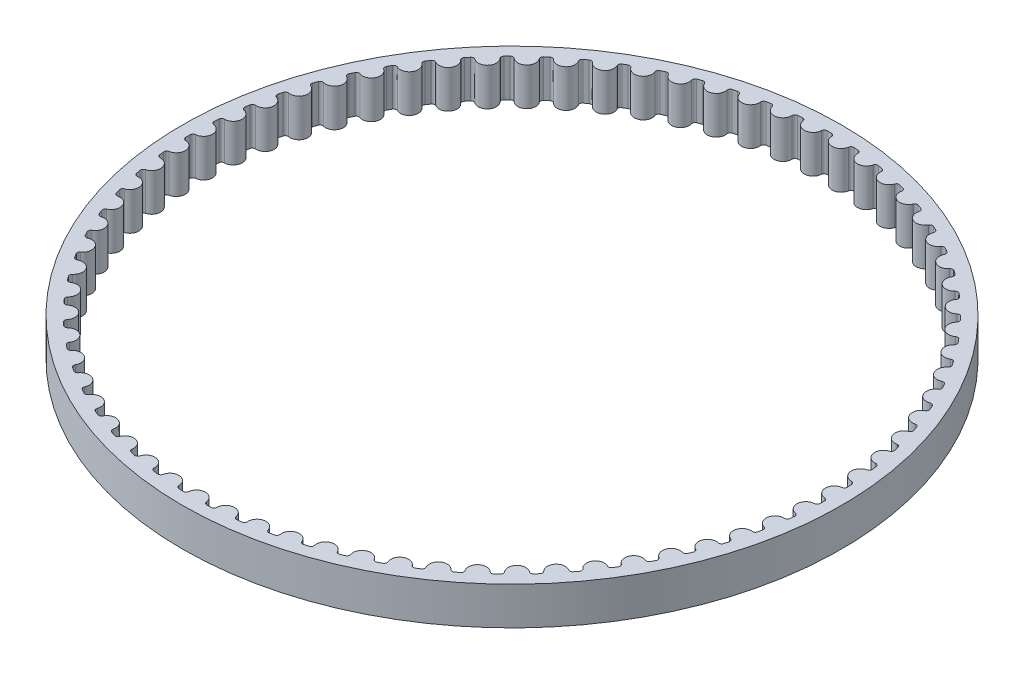
from build123d import *

# Parameters (mm, degrees)
SKETCH1_R           = 34.819002879
BOSS_EXTRUDE1_DEPTH = 4


with BuildPart() as part:
    # Sketch1 → Boss-Extrude1 (new body)
    with BuildSketch(Plane(origin=(0, 0, 0), x_dir=(1, 0, 0), z_dir=(0, 1, 0))):
        Circle(SKETCH1_R)
        with BuildLine():
            ThreePointArc((-1.717893516, -33.474951768), (-1.482657676, -33.486195367), (-1.247348646, -33.495785934))
            ThreePointArc((-1.247348646, -33.495785934), (-1.040464192, -33.423001703), (-0.938899541, -33.228622323))
            ThreePointArc((-0.938899541, -33.228622323), (0, -32.384305614), (0.938899541, -33.228622323))
            ThreePointArc((0.938899541, -33.228622323), (1.040464192, -33.423001703), (1.247348646, -33.495785934))
            ThreePointArc((1.247348646, -33.495785934), (1.482657676, -33.486195367), (1.717893516, -33.474951768))
            ThreePointArc((1.717893516, -33.474951768), (1.917535716, -33.384167885), (2.001523656, -33.181572851))
            ThreePointArc((2.001523656, -33.181572851), (2.862128318, -32.257580065), (3.871974577, -33.015612772))
            ThreePointArc((3.871974577, -33.015612772), (3.990321057, -33.200255217), (4.202828613, -33.25447016))
            ThreePointArc((4.202828613, -33.25447016), (4.436369222, -33.224120486), (4.669690832, -33.192130717))
            ThreePointArc((4.669690832, -33.192130717), (4.860528308, -33.084057689), (4.926282217, -32.874832583))
            ThreePointArc((4.926282217, -32.874832583), (5.7018566, -31.878395214), (6.774746161, -32.544211287))
            ThreePointArc((6.774746161, -32.544211287), (6.908948249, -32.717671719), (7.125415748, -32.752893069))
            ThreePointArc((7.125415748, -32.752893069), (7.355360164, -32.702021816), (7.584941485, -32.649536239))
            ThreePointArc((7.584941485, -32.649536239), (7.765480675, -32.525019884), (7.812485941, -32.310802176))
            ThreePointArc((7.812485941, -32.310802176), (8.496960124, -31.249718699), (9.624496172, -31.818107223))
            ThreePointArc((9.624496172, -31.818107223), (9.773503554, -31.979028079), (9.992236844, -31.994980182))
            ThreePointArc((9.992236844, -31.994980182), (10.216785439, -31.923985485), (10.440829687, -31.851414873))
            ThreePointArc((10.440829687, -31.851414873), (10.609657626, -31.7114297), (10.637546369, -31.493895934))
            ThreePointArc((10.637546369, -31.493895934), (11.225563415, -30.376470765), (12.39892145, -30.84298333))
            ThreePointArc((12.39892145, -30.84298333), (12.561567942, -30.990105186), (12.780855138, -30.986663194))
            ThreePointArc((12.780855138, -30.986663194), (12.998250516, -30.896100684), (13.215004241, -30.804013))
            ThreePointArc((13.215004241, -30.804013), (13.370799622, -30.649654583), (13.379353575, -30.430507255))
            ThreePointArc((13.379353575, -30.430507255), (13.866311451, -29.265485762), (15.076308358, -29.626471274))
            ThreePointArc((15.076308358, -29.626471274), (15.251321029, -29.758642702), (15.469445912, -29.735833554))
            ThreePointArc((15.469445912, -29.735833554), (15.67798666, -29.626412005), (15.885753469, -29.515527959))
            ThreePointArc((15.885753469, -29.515527959), (16.027296982, -29.348004362), (16.016449198, -29.128958597))
            ThreePointArc((16.016449198, -29.128958597), (16.3985368, -27.925458652), (17.635702711, -28.178091911))
            ThreePointArc((17.635702711, -28.178091911), (17.821711851, -28.29427849), (18.036967298, -28.252280699))
            ThreePointArc((18.036967298, -28.252280699), (18.2350213, -28.124856482), (18.432175138, -27.996043893))
            ThreePointArc((18.432175138, -27.996043893), (18.558359013, -27.816666215), (18.52819439, -27.599436344))
            ThreePointArc((18.52819439, -27.599436344), (18.802421365, -26.366876966), (20.057073778, -26.509180774))
            ThreePointArc((20.057073778, -26.509180774), (20.252623614, -26.608473187), (20.463324959, -26.547615441))
            ThreePointArc((20.463324959, -26.547615441), (20.649342175, -26.403185825), (20.834340044, -26.257452826))
            ThreePointArc((20.834340044, -26.257452826), (20.944176722, -26.067624941), (20.894931339, -25.853911081))
            ThreePointArc((20.894931339, -25.853911081), (21.059151489, -24.601938718), (22.32147105, -24.632799354))
            ThreePointArc((22.32147105, -24.632799354), (22.525031138, -24.714420503), (22.729529357, -24.635179098))
            ThreePointArc((22.729529357, -24.635179098), (22.90205395, -24.47487444), (23.073447992, -24.313361589))
            ThreePointArc((23.073447992, -24.313361589), (23.16607785, -24.114569157), (23.098137121, -23.906043909))
            ThreePointArc((23.098137121, -23.906043909), (23.151065199, -22.644456944), (24.411172545, -22.563632881))
            ThreePointArc((24.411172545, -22.563632881), (24.621149753, -22.626943971), (24.81784437, -22.529939077))
            ThreePointArc((24.81784437, -22.529939077), (24.975526101, -22.355013978), (25.131974925, -22.178985332))
            ThreePointArc((25.131974925, -22.178985332), (25.20667301, -21.972784174), (25.120568662, -21.771079531))
            ThreePointArc((25.120568662, -21.771079531), (25.061790435, -20.509751591), (26.309823518, -20.317875388))
            ThreePointArc((26.309823518, -20.317875388), (26.524574488, -20.362380922), (26.711926101, -20.248371736))
            ThreePointArc((26.711926101, -20.248371736), (26.853530897, -20.060195222), (26.993810079, -19.871028443))
            ThreePointArc((26.993810079, -19.871028443), (27.049991778, -19.659032362), (26.946397693, -19.465726937))
            ThreePointArc((26.946397693, -19.465726937), (26.776373181, -18.214529624), (28.002564449, -17.913102972))
            ThreePointArc((28.002564449, -17.913102972), (28.220408464, -17.938454635), (28.396950793, -17.808333432))
            ThreePointArc((28.396950793, -17.808333432), (28.521370405, -17.608378239), (28.644382069, -17.407553815))
            ThreePointArc((28.644382069, -17.407553815), (28.681607683, -17.191421968), (28.561334627, -17.008028638))
            ThreePointArc((28.561334627, -17.008028638), (28.281394502, -15.776754266), (29.476147347, -15.368136238))
            ThreePointArc((29.476147347, -15.368136238), (29.695379482, -15.374135619), (29.859730844, -15.228920773))
            ThreePointArc((29.859730844, -15.228920773), (29.965991518, -15.018751822), (30.070772933, -14.807841476))
            ThreePointArc((30.070772933, -14.807841476), (30.088751121, -14.589265388), (29.952740393, -14.417219454))
            ThreePointArc((29.952740393, -14.417219454), (29.565075565, -13.215504415), (30.719039426, -12.702893001))
            ThreePointArc((30.719039426, -12.702893001), (30.937943892, -12.689493146), (31.088818015, -12.530321161))
            ThreePointArc((31.088818015, -12.530321161), (31.176088119, -12.311583309), (31.261819227, -12.092237701))
            ThreePointArc((31.261819227, -12.092237701), (31.260409285, -11.872928026), (31.109725354, -11.71357598))
            ThreePointArc((31.109725354, -11.71357598), (30.617369827, -10.550825324), (31.721513371, -9.938232403))
            ThreePointArc((31.721513371, -9.938232403), (31.938376945, -9.905538184), (32.074593034, -9.733654797))
            ThreePointArc((32.074593034, -9.733654797), (32.14218956, -9.508059965), (32.208199399, -9.28199577))
            ThreePointArc((32.208199399, -9.28199577), (32.187412363, -9.063668903), (32.023234534, -8.918257892))
            ThreePointArc((32.023234534, -8.918257892), (31.430041657, -7.80357172), (32.475723464, -7.095791662))
            ThreePointArc((32.475723464, -7.095791662), (32.688848894, -7.044058956), (32.809340873, -6.860809387))
            ThreePointArc((32.809340873, -6.860809387), (32.856734787, -6.630123159), (32.902506741, -6.399109638))
            ThreePointArc((32.902506741, -6.399109638), (32.862505297, -6.183474283), (32.686118485, -6.053142345))
            ThreePointArc((32.686118485, -6.053142345), (31.996730796, -4.995244586), (32.975766989, -4.19781673))
            ThreePointArc((32.975766989, -4.19781673), (33.183486279, -4.127450415), (33.287311136, -3.934268841))
            ThreePointArc((33.287311136, -3.934268841), (33.314131516, -3.70029665), (33.339307357, -3.466141796))
            ThreePointArc((33.339307357, -3.466141796), (33.28040457, -3.254885593), (33.093189241, -3.140652751))
            ThreePointArc((33.093189241, -3.140652751), (32.313002135, -2.14782289), (33.217730428, -1.26698819))
            ThreePointArc((33.217730428, -1.26698819), (33.418417893, -1.178538979), (33.504763057, -0.976937307))
            ThreePointArc((33.504763057, -0.976937307), (33.510799997, -0.741510303), (33.51518269, -0.506046695))
            ThreePointArc((33.51518269, -0.506046695), (33.437839555, -0.300823009), (33.241260922, -0.203583292))
            ThreePointArc((33.241260922, -0.203583292), (32.37638042, 0.716408431), (33.199720087, 1.67375625))
            ThreePointArc((33.199720087, 1.67375625), (33.391805076, 1.779596122), (33.459994779, 1.988040086))
            ThreePointArc((33.459994779, 1.988040086), (33.445201032, 2.223079368), (33.428756276, 2.458008908))
            ThreePointArc((33.428756276, 2.458008908), (33.333578108, 2.655593922), (33.129174666, 2.735079483))
            ThreePointArc((33.129174666, 2.735079483), (32.186369631, 3.575032886), (32.921876923, 4.601401277))
            ThreePointArc((32.921876923, 4.601401277), (33.10385611, 4.723803471), (33.153356675, 4.93745837))
            ThreePointArc((33.153356675, 4.93745837), (33.117848023, 5.170270428), (33.080704521, 5.402827258))
            ThreePointArc((33.080704521, 5.402827258), (32.968436218, 5.591227231), (32.7578077, 5.652336553))
            ThreePointArc((32.7578077, 5.652336553), (31.744456859, 6.40567786), (32.386375435, 7.493034102))
            ThreePointArc((32.386375435, 7.493034102), (32.556824586, 7.631040653), (32.587248604, 7.848234347))
            ThreePointArc((32.587248604, 7.848234347), (32.53130295, 8.076997112), (32.4737514, 8.305361159))
            ThreePointArc((32.4737514, 8.305361159), (32.345271613, 8.483101605), (32.130066475, 8.525356425))
            ThreePointArc((32.130066475, 8.525356425), (31.054100672, 9.186189721), (31.597406648, 10.326023774))
            ThreePointArc((31.597406648, 10.326023774), (31.754991768, 10.478554596), (31.76610113, 10.69758725))
            ThreePointArc((31.76610113, 10.69758725), (31.690156324, 10.920510343), (31.612647145, 11.142894349))
            ThreePointArc((31.612647145, 11.142894349), (31.468961403, 11.308584207), (31.250863915, 11.331653824))
            ThreePointArc((31.250863915, 11.331653824), (30.120704042, 11.894807191), (30.561145312, 13.078198311))
            ThreePointArc((30.561145312, 13.078198311), (30.704633084, 13.244059641), (30.696340844, 13.463217029))
            ThreePointArc((30.696340844, 13.463217029), (30.600991257, 13.678555773), (30.504131064, 13.893219282))
            ThreePointArc((30.504131064, 13.893219282), (30.346363903, 14.045561806), (30.127080974, 14.049265668))
            ThreePointArc((30.127080974, 14.049265668), (28.951572064, 14.510331668), (29.285701578, 15.728018213))
            ThreePointArc((29.285701578, 15.728018213), (29.413969015, 15.905911963), (29.386340072, 16.123478879))
            ThreePointArc((29.386340072, 16.123478879), (29.272331944, 16.329547959), (29.156878798, 16.534810937))
            ThreePointArc((29.156878798, 16.534810937), (28.98626496, 16.672613839), (28.767512777, 16.65692296))
            ThreePointArc((28.767512777, 16.65692296), (27.555854781, 17.012293126), (27.781057523, 18.254745048))
            ThreePointArc((27.781057523, 18.254745048), (27.893100758, 18.443278958), (27.846351344, 18.657552647))
            ThreePointArc((27.846351344, 18.657552647), (27.714576944, 18.852739291), (27.581434424, 19.046995278))
            ThreePointArc((27.581434424, 19.046995278), (27.399309193, 19.169180064), (27.182799787, 19.134217245))
            ThreePointArc((27.182799787, 19.134217245), (25.944475573, 19.381110324), (26.058989025, 20.638603752))
            ThreePointArc((26.058989025, 20.638603752), (26.153931168, 20.836302288), (26.088427163, 21.045605768))
            ThreePointArc((26.088427163, 21.045605768), (25.939917803, 21.228382377), (25.790127929, 21.410111055))
            ThreePointArc((25.790127929, 21.410111055), (25.597916682, 21.515721464), (25.385344534, 21.461760337))
            ThreePointArc((25.385344534, 21.461760337), (24.130045666, 21.598244056), (24.132973606, 22.860937399))
            ThreePointArc((24.132973606, 22.860937399), (24.210071606, 23.066253302), (24.126325666, 23.26894849))
            ThreePointArc((24.126325666, 23.26894849), (23.962243634, 23.437884589), (23.796978715, 23.605663685))
            ThreePointArc((23.796978715, 23.605663685), (23.596185766, 23.693873172), (23.38921454, 23.621336055))
            ThreePointArc((23.38921454, 23.621336055), (22.126765435, 23.646342244), (22.018084948, 24.904353215))
            ThreePointArc((22.018084948, 24.904353215), (22.076735409, 25.11567961), (21.97540296, 25.31018014))
            ThreePointArc((21.97540296, 25.31018014), (21.79703242, 25.463953575), (21.617585877, 25.616469991))
            ThreePointArc((21.617585877, 25.616469991), (21.409782704, 25.686588196), (21.210032231, 25.596042792))
            ThreePointArc((21.210032231, 25.596042792), (19.950313264, 25.509375743), (19.730874922, 26.752858701))
            ThreePointArc((19.730874922, 26.752858701), (19.770618825, 26.968541671), (19.65249293, 27.153325314))
            ThreePointArc((19.65249293, 27.153325314), (19.461229873, 27.290732599), (19.26900612, 27.426792687))
            ThreePointArc((19.26900612, 27.426792687), (19.055819063, 27.478270841), (18.864852662, 27.370425789))
            ThreePointArc((18.864852662, 27.370425789), (17.617722842, 27.17276379), (17.289244047, 28.391986794))
            ThreePointArc((17.289244047, 28.391986794), (17.309770342, 28.610338329), (17.175775497, 28.783958902))
            ThreePointArc((17.175775497, 28.783958902), (16.973116816, 28.903924639), (16.769620264, 29.022463544))
            ThreePointArc((16.769620264, 29.022463544), (16.552717802, 29.05489876), (16.372030043, 28.930598095))
            ThreePointArc((16.372030043, 28.930598095), (15.147249852, 28.623488118), (14.712301397, 29.808909095))
            ThreePointArc((14.712301397, 29.808909095), (14.713449436, 30.028220298), (14.564634333, 30.189318984))
            ThreePointArc((14.564634333, 30.189318984), (14.352166108, 30.290904278), (14.138989393, 30.390994273))
            ThreePointArc((14.138989393, 30.390994273), (13.92006908, 30.404132702), (13.751074091, 30.264349245))
            ThreePointArc((13.751074091, 30.264349245), (12.558229095, 29.850194842), (12.02021504, 30.992536267))
            ThreePointArc((12.02021504, 30.992536267), (12.00197584, 31.211090729), (11.839505158, 31.358406713))
            ThreePointArc((11.839505158, 31.358406713), (11.618890239, 31.440816522), (11.397701759, 31.521674267))
            ThreePointArc((11.397701759, 31.521674267), (11.178476945, 31.515413083), (11.022497339, 31.361240828))
            ThreePointArc((11.022497339, 31.361240828), (9.870923167, 30.84328332), (9.234054203, 31.93360482))
            ThreePointArc((9.234054203, 31.93360482), (9.19657051, 32.149692058), (9.021715802, 32.282072393))
            ThreePointArc((9.021715802, 32.282072393), (8.794680802, 32.344661748), (8.567211655, 32.405654421))
            ThreePointArc((8.567211655, 32.405654421), (8.349398071, 32.380042626), (8.207654601, 32.21268818))
            ThreePointArc((8.207654601, 32.21268818), (7.106363883, 31.594981286), (6.375624371, 32.624749619))
            ThreePointArc((6.375624371, 32.624749619), (6.319189546, 32.836678457), (6.133319289, 32.953087086))
            ThreePointArc((6.133319289, 32.953087086), (5.901641063, 32.99536614), (5.669671505, 33.036016391))
            ThreePointArc((5.669671505, 33.036016391), (5.454973836, 32.991254433), (5.328575838, 32.812027572))
            ThreePointArc((5.328575838, 32.812027572), (4.286187666, 32.099405686), (3.467296635, 33.060561518))
            ThreePointArc((3.467296635, 33.060561518), (3.392352357, 33.266673324), (3.196921235, 33.366199193))
            ThreePointArc((3.196921235, 33.366199193), (2.96241298, 33.387837056), (2.727758487, 33.407826742))
            ThreePointArc((2.727758487, 33.407826742), (2.517857036, 33.344264942), (2.407793744, 33.15456836))
            ThreePointArc((2.407793744, 33.15456836), (1.432466219, 32.352608715), (0.531832601, 33.237629698))
            ThreePointArc((0.531832601, 33.237629698), (0.43896541, 33.436311369), (0.235502939, 33.518175552))
            ThreePointArc((0.235502939, 33.518175552), (0, 33.519002879), (-0.235502939, 33.518175552))
            ThreePointArc((-0.235502939, 33.518175552), (-0.43896541, 33.436311369), (-0.531832601, 33.237629698))
            ThreePointArc((-0.531832601, 33.237629698), (-1.432466219, 32.352608715), (-2.407793744, 33.15456836))
            ThreePointArc((-2.407793744, 33.15456836), (-2.517857036, 33.344264942), (-2.727758487, 33.407826742))
            ThreePointArc((-2.727758487, 33.407826742), (-2.96241298, 33.387837056), (-3.196921235, 33.366199193))
            ThreePointArc((-3.196921235, 33.366199193), (-3.392352357, 33.266673324), (-3.467296635, 33.060561518))
            ThreePointArc((-3.467296635, 33.060561518), (-4.286187666, 32.099405686), (-5.328575838, 32.812027572))
            ThreePointArc((-5.328575838, 32.812027572), (-5.454973836, 32.991254433), (-5.669671505, 33.036016391))
            ThreePointArc((-5.669671505, 33.036016391), (-5.901641063, 32.99536614), (-6.133319289, 32.953087086))
            ThreePointArc((-6.133319289, 32.953087086), (-6.319189546, 32.836678457), (-6.375624371, 32.624749619))
            ThreePointArc((-6.375624371, 32.624749619), (-7.106363883, 31.594981286), (-8.207654601, 32.21268818))
            ThreePointArc((-8.207654601, 32.21268818), (-8.349398071, 32.380042626), (-8.567211655, 32.405654421))
            ThreePointArc((-8.567211655, 32.405654421), (-8.794680802, 32.344661748), (-9.021715802, 32.282072393))
            ThreePointArc((-9.021715802, 32.282072393), (-9.19657051, 32.149692058), (-9.234054203, 31.93360482))
            ThreePointArc((-9.234054203, 31.93360482), (-9.870923167, 30.84328332), (-11.022497339, 31.361240828))
            ThreePointArc((-11.022497339, 31.361240828), (-11.178476945, 31.515413083), (-11.397701759, 31.521674267))
            ThreePointArc((-11.397701759, 31.521674267), (-11.618890239, 31.440816522), (-11.839505158, 31.358406713))
            ThreePointArc((-11.839505158, 31.358406713), (-12.00197584, 31.211090729), (-12.02021504, 30.992536267))
            ThreePointArc((-12.02021504, 30.992536267), (-12.558229095, 29.850194842), (-13.751074091, 30.264349245))
            ThreePointArc((-13.751074091, 30.264349245), (-13.92006908, 30.404132702), (-14.138989393, 30.390994273))
            ThreePointArc((-14.138989393, 30.390994273), (-14.352166108, 30.290904278), (-14.564634333, 30.189318984))
            ThreePointArc((-14.564634333, 30.189318984), (-14.713449436, 30.028220298), (-14.712301397, 29.808909095))
            ThreePointArc((-14.712301397, 29.808909095), (-15.147249852, 28.623488118), (-16.372030043, 28.930598095))
            ThreePointArc((-16.372030043, 28.930598095), (-16.552717802, 29.05489876), (-16.769620264, 29.022463544))
            ThreePointArc((-16.769620264, 29.022463544), (-16.973116816, 28.903924639), (-17.175775497, 28.783958902))
            ThreePointArc((-17.175775497, 28.783958902), (-17.309770342, 28.610338329), (-17.289244047, 28.391986794))
            ThreePointArc((-17.289244047, 28.391986794), (-17.617722842, 27.17276379), (-18.864852662, 27.370425789))
            ThreePointArc((-18.864852662, 27.370425789), (-19.055819063, 27.478270841), (-19.26900612, 27.426792687))
            ThreePointArc((-19.26900612, 27.426792687), (-19.461229873, 27.290732599), (-19.65249293, 27.153325314))
            ThreePointArc((-19.65249293, 27.153325314), (-19.770618825, 26.968541671), (-19.730874922, 26.752858701))
            ThreePointArc((-19.730874922, 26.752858701), (-19.950313264, 25.509375743), (-21.210032231, 25.596042792))
            ThreePointArc((-21.210032231, 25.596042792), (-21.409782704, 25.686588196), (-21.617585877, 25.616469991))
            ThreePointArc((-21.617585877, 25.616469991), (-21.79703242, 25.463953575), (-21.97540296, 25.31018014))
            ThreePointArc((-21.97540296, 25.31018014), (-22.076735409, 25.11567961), (-22.018084948, 24.904353215))
            ThreePointArc((-22.018084948, 24.904353215), (-22.126765435, 23.646342244), (-23.38921454, 23.621336055))
            ThreePointArc((-23.38921454, 23.621336055), (-23.596185766, 23.693873172), (-23.796978715, 23.605663685))
            ThreePointArc((-23.796978715, 23.605663685), (-23.962243634, 23.437884589), (-24.126325666, 23.26894849))
            ThreePointArc((-24.126325666, 23.26894849), (-24.210071606, 23.066253302), (-24.132973606, 22.860937399))
            ThreePointArc((-24.132973606, 22.860937399), (-24.130045666, 21.598244056), (-25.385344534, 21.461760337))
            ThreePointArc((-25.385344534, 21.461760337), (-25.597916682, 21.515721464), (-25.790127929, 21.410111055))
            ThreePointArc((-25.790127929, 21.410111055), (-25.939917803, 21.228382377), (-26.088427163, 21.045605768))
            ThreePointArc((-26.088427163, 21.045605768), (-26.153931168, 20.836302288), (-26.058989025, 20.638603752))
            ThreePointArc((-26.058989025, 20.638603752), (-25.944475573, 19.381110324), (-27.182799787, 19.134217245))
            ThreePointArc((-27.182799787, 19.134217245), (-27.399309193, 19.169180064), (-27.581434424, 19.046995278))
            ThreePointArc((-27.581434424, 19.046995278), (-27.714576944, 18.852739291), (-27.846351344, 18.657552647))
            ThreePointArc((-27.846351344, 18.657552647), (-27.893100758, 18.443278958), (-27.781057523, 18.254745048))
            ThreePointArc((-27.781057523, 18.254745048), (-27.555854781, 17.012293126), (-28.767512777, 16.65692296))
            ThreePointArc((-28.767512777, 16.65692296), (-28.98626496, 16.672613839), (-29.156878798, 16.534810937))
            ThreePointArc((-29.156878798, 16.534810937), (-29.272331944, 16.329547959), (-29.386340072, 16.123478879))
            ThreePointArc((-29.386340072, 16.123478879), (-29.413969015, 15.905911963), (-29.285701578, 15.728018213))
            ThreePointArc((-29.285701578, 15.728018213), (-28.951572064, 14.510331668), (-30.127080974, 14.049265668))
            ThreePointArc((-30.127080974, 14.049265668), (-30.346363903, 14.045561806), (-30.504131064, 13.893219282))
            ThreePointArc((-30.504131064, 13.893219282), (-30.600991257, 13.678555773), (-30.696340844, 13.463217029))
            ThreePointArc((-30.696340844, 13.463217029), (-30.704633084, 13.244059641), (-30.561145312, 13.078198311))
            ThreePointArc((-30.561145312, 13.078198311), (-30.120704042, 11.894807191), (-31.250863915, 11.331653824))
            ThreePointArc((-31.250863915, 11.331653824), (-31.468961403, 11.308584207), (-31.612647145, 11.142894349))
            ThreePointArc((-31.612647145, 11.142894349), (-31.690156324, 10.920510343), (-31.76610113, 10.69758725))
            ThreePointArc((-31.76610113, 10.69758725), (-31.754991768, 10.478554596), (-31.597406648, 10.326023774))
            ThreePointArc((-31.597406648, 10.326023774), (-31.054100672, 9.186189721), (-32.130066475, 8.525356425))
            ThreePointArc((-32.130066475, 8.525356425), (-32.345271613, 8.483101605), (-32.4737514, 8.305361159))
            ThreePointArc((-32.4737514, 8.305361159), (-32.53130295, 8.076997112), (-32.587248604, 7.848234347))
            ThreePointArc((-32.587248604, 7.848234347), (-32.556824586, 7.631040653), (-32.386375435, 7.493034102))
            ThreePointArc((-32.386375435, 7.493034102), (-31.744456859, 6.40567786), (-32.7578077, 5.652336553))
            ThreePointArc((-32.7578077, 5.652336553), (-32.968436218, 5.591227231), (-33.080704521, 5.402827258))
            ThreePointArc((-33.080704521, 5.402827258), (-33.117848023, 5.170270428), (-33.153356675, 4.93745837))
            ThreePointArc((-33.153356675, 4.93745837), (-33.10385611, 4.723803471), (-32.921876923, 4.601401277))
            ThreePointArc((-32.921876923, 4.601401277), (-32.186369631, 3.575032886), (-33.129174666, 2.735079483))
            ThreePointArc((-33.129174666, 2.735079483), (-33.333578108, 2.655593922), (-33.428756276, 2.458008908))
            ThreePointArc((-33.428756276, 2.458008908), (-33.445201032, 2.223079368), (-33.459994779, 1.988040086))
            ThreePointArc((-33.459994779, 1.988040086), (-33.391805076, 1.779596122), (-33.199720087, 1.67375625))
            ThreePointArc((-33.199720087, 1.67375625), (-32.37638042, 0.716408431), (-33.241260922, -0.203583292))
            ThreePointArc((-33.241260922, -0.203583292), (-33.437839555, -0.300823009), (-33.51518269, -0.506046695))
            ThreePointArc((-33.51518269, -0.506046695), (-33.510799997, -0.741510303), (-33.504763057, -0.976937307))
            ThreePointArc((-33.504763057, -0.976937307), (-33.418417893, -1.178538979), (-33.217730428, -1.26698819))
            ThreePointArc((-33.217730428, -1.26698819), (-32.313002135, -2.14782289), (-33.093189241, -3.140652751))
            ThreePointArc((-33.093189241, -3.140652751), (-33.28040457, -3.254885593), (-33.339307357, -3.466141796))
            ThreePointArc((-33.339307357, -3.466141796), (-33.314131516, -3.70029665), (-33.287311136, -3.934268841))
            ThreePointArc((-33.287311136, -3.934268841), (-33.183486279, -4.127450415), (-32.975766989, -4.19781673))
            ThreePointArc((-32.975766989, -4.19781673), (-31.996730796, -4.995244586), (-32.686118485, -6.053142345))
            ThreePointArc((-32.686118485, -6.053142345), (-32.862505297, -6.183474283), (-32.902506741, -6.399109638))
            ThreePointArc((-32.902506741, -6.399109638), (-32.856734787, -6.630123159), (-32.809340873, -6.860809387))
            ThreePointArc((-32.809340873, -6.860809387), (-32.688848894, -7.044058956), (-32.475723464, -7.095791662))
            ThreePointArc((-32.475723464, -7.095791662), (-31.430041657, -7.80357172), (-32.023234534, -8.918257892))
            ThreePointArc((-32.023234534, -8.918257892), (-32.187412363, -9.063668903), (-32.208199399, -9.28199577))
            ThreePointArc((-32.208199399, -9.28199577), (-32.14218956, -9.508059965), (-32.074593034, -9.733654797))
            ThreePointArc((-32.074593034, -9.733654797), (-31.938376945, -9.905538184), (-31.721513371, -9.938232403))
            ThreePointArc((-31.721513371, -9.938232403), (-30.617369827, -10.550825324), (-31.109725354, -11.71357598))
            ThreePointArc((-31.109725354, -11.71357598), (-31.260409285, -11.872928026), (-31.261819227, -12.092237701))
            ThreePointArc((-31.261819227, -12.092237701), (-31.176088119, -12.311583309), (-31.088818015, -12.530321161))
            ThreePointArc((-31.088818015, -12.530321161), (-30.937943892, -12.689493146), (-30.719039426, -12.702893001))
            ThreePointArc((-30.719039426, -12.702893001), (-29.565075565, -13.215504415), (-29.952740393, -14.417219454))
            ThreePointArc((-29.952740393, -14.417219454), (-30.088751121, -14.589265388), (-30.070772933, -14.807841476))
            ThreePointArc((-30.070772933, -14.807841476), (-29.965991518, -15.018751822), (-29.859730844, -15.228920773))
            ThreePointArc((-29.859730844, -15.228920773), (-29.695379482, -15.374135619), (-29.476147347, -15.368136238))
            ThreePointArc((-29.476147347, -15.368136238), (-28.281394502, -15.776754266), (-28.561334627, -17.008028638))
            ThreePointArc((-28.561334627, -17.008028638), (-28.681607683, -17.191421968), (-28.644382069, -17.407553815))
            ThreePointArc((-28.644382069, -17.407553815), (-28.521370405, -17.608378239), (-28.396950793, -17.808333432))
            ThreePointArc((-28.396950793, -17.808333432), (-28.220408464, -17.938454635), (-28.002564449, -17.913102972))
            ThreePointArc((-28.002564449, -17.913102972), (-26.776373181, -18.214529624), (-26.946397693, -19.465726937))
            ThreePointArc((-26.946397693, -19.465726937), (-27.049991778, -19.659032362), (-26.993810079, -19.871028443))
            ThreePointArc((-26.993810079, -19.871028443), (-26.853530897, -20.060195222), (-26.711926101, -20.248371736))
            ThreePointArc((-26.711926101, -20.248371736), (-26.524574488, -20.362380922), (-26.309823518, -20.317875388))
            ThreePointArc((-26.309823518, -20.317875388), (-25.061790435, -20.509751591), (-25.120568662, -21.771079531))
            ThreePointArc((-25.120568662, -21.771079531), (-25.20667301, -21.972784174), (-25.131974925, -22.178985332))
            ThreePointArc((-25.131974925, -22.178985332), (-24.975526101, -22.355013978), (-24.81784437, -22.529939077))
            ThreePointArc((-24.81784437, -22.529939077), (-24.621149753, -22.626943971), (-24.411172545, -22.563632881))
            ThreePointArc((-24.411172545, -22.563632881), (-23.151065199, -22.644456944), (-23.098137121, -23.906043909))
            ThreePointArc((-23.098137121, -23.906043909), (-23.16607785, -24.114569157), (-23.073447992, -24.313361589))
            ThreePointArc((-23.073447992, -24.313361589), (-22.90205395, -24.47487444), (-22.729529357, -24.635179098))
            ThreePointArc((-22.729529357, -24.635179098), (-22.525031138, -24.714420503), (-22.32147105, -24.632799354))
            ThreePointArc((-22.32147105, -24.632799354), (-21.059151489, -24.601938718), (-20.894931339, -25.853911081))
            ThreePointArc((-20.894931339, -25.853911081), (-20.944176722, -26.067624941), (-20.834340044, -26.257452826))
            ThreePointArc((-20.834340044, -26.257452826), (-20.649342175, -26.403185825), (-20.463324959, -26.547615441))
            ThreePointArc((-20.463324959, -26.547615441), (-20.252623614, -26.608473187), (-20.057073778, -26.509180774))
            ThreePointArc((-20.057073778, -26.509180774), (-18.802421365, -26.366876966), (-18.52819439, -27.599436344))
            ThreePointArc((-18.52819439, -27.599436344), (-18.558359013, -27.816666215), (-18.432175138, -27.996043893))
            ThreePointArc((-18.432175138, -27.996043893), (-18.2350213, -28.124856482), (-18.036967298, -28.252280699))
            ThreePointArc((-18.036967298, -28.252280699), (-17.821711851, -28.29427849), (-17.635702711, -28.178091911))
            ThreePointArc((-17.635702711, -28.178091911), (-16.3985368, -27.925458652), (-16.016449198, -29.128958597))
            ThreePointArc((-16.016449198, -29.128958597), (-16.027296982, -29.348004362), (-15.885753469, -29.515527959))
            ThreePointArc((-15.885753469, -29.515527959), (-15.67798666, -29.626412005), (-15.469445912, -29.735833554))
            ThreePointArc((-15.469445912, -29.735833554), (-15.251321029, -29.758642702), (-15.076308358, -29.626471274))
            ThreePointArc((-15.076308358, -29.626471274), (-13.866311451, -29.265485762), (-13.379353575, -30.430507255))
            ThreePointArc((-13.379353575, -30.430507255), (-13.370799622, -30.649654583), (-13.215004241, -30.804013))
            ThreePointArc((-13.215004241, -30.804013), (-12.998250516, -30.896100684), (-12.780855138, -30.986663194))
            ThreePointArc((-12.780855138, -30.986663194), (-12.561567942, -30.990105186), (-12.39892145, -30.84298333))
            ThreePointArc((-12.39892145, -30.84298333), (-11.225563415, -30.376470765), (-10.637546369, -31.493895934))
            ThreePointArc((-10.637546369, -31.493895934), (-10.609657626, -31.7114297), (-10.440829687, -31.851414873))
            ThreePointArc((-10.440829687, -31.851414873), (-10.216785439, -31.923985485), (-9.992236844, -31.994980182))
            ThreePointArc((-9.992236844, -31.994980182), (-9.773503554, -31.979028079), (-9.624496172, -31.818107223))
            ThreePointArc((-9.624496172, -31.818107223), (-8.496960124, -31.249718699), (-7.812485941, -32.310802176))
            ThreePointArc((-7.812485941, -32.310802176), (-7.765480675, -32.525019884), (-7.584941485, -32.649536239))
            ThreePointArc((-7.584941485, -32.649536239), (-7.355360164, -32.702021816), (-7.125415748, -32.752893069))
            ThreePointArc((-7.125415748, -32.752893069), (-6.908948249, -32.717671719), (-6.774746161, -32.544211287))
            ThreePointArc((-6.774746161, -32.544211287), (-5.7018566, -31.878395214), (-4.926282217, -32.874832583))
            ThreePointArc((-4.926282217, -32.874832583), (-4.860528308, -33.084057689), (-4.669690832, -33.192130717))
            ThreePointArc((-4.669690832, -33.192130717), (-4.436369222, -33.224120486), (-4.202828613, -33.25447016))
            ThreePointArc((-4.202828613, -33.25447016), (-3.990321057, -33.200255217), (-3.871974577, -33.015612772))
            ThreePointArc((-3.871974577, -33.015612772), (-2.862128318, -32.257580065), (-2.001523656, -33.181572851))
            ThreePointArc((-2.001523656, -33.181572851), (-1.917535716, -33.384167885), (-1.717893516, -33.474951768))
        make_face(mode=Mode.SUBTRACT)
    extrude(amount=BOSS_EXTRUDE1_DEPTH)


solid = part.part
